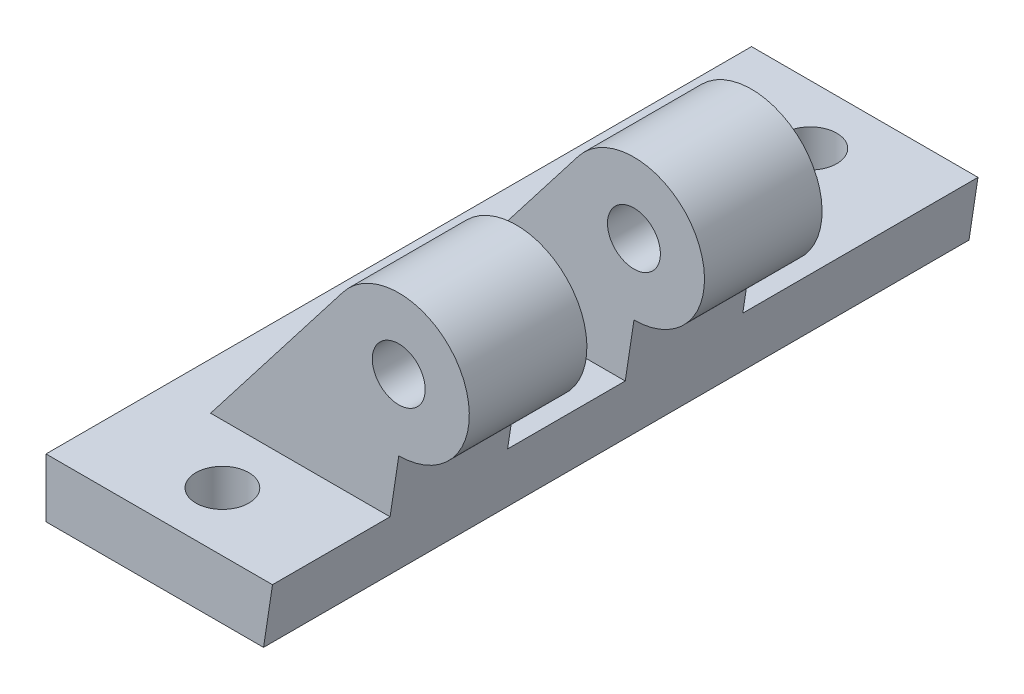
from build123d import *

# Parameters (mm, degrees)
SKETCH1_W           = 20
SKETCH1_H           = 60
SKETCH1_R           = 2.25
BOSS_EXTRUDE1_DEPTH = 5
SKETCH2_R           = 2.25
BOSS_EXTRUDE2_DEPTH = 10
SKETCH3_R           = 2.25
BOSS_EXTRUDE3_DEPTH = 10
CUT_EXTRUDE1_DEPTH  = 61


with BuildPart() as part:
    # Sketch1 → Boss-Extrude1 (new body)
    with BuildSketch(Plane(origin=(0, 0, 0), x_dir=(1, 0, 0), z_dir=(0, 1, 0))):
        Rectangle(SKETCH1_W, SKETCH1_H)
        with Locations((0, 25)):
            Circle(SKETCH1_R, mode=Mode.SUBTRACT)
        with Locations((0, -25)):
            Circle(SKETCH1_R, mode=Mode.SUBTRACT)
    extrude(amount=BOSS_EXTRUDE1_DEPTH)

    # Sketch2 → Boss-Extrude2 (add)
    with BuildSketch(Plane.XY.offset(20)):
        with BuildLine():
            Line((10, 9.86530346), (10, 5))
            Line((10, 5), (-6, 5))
            Line((-6, 5), (5.255684086, 19.53837663))
            ThreePointArc((5.255684086, 19.53837663), (15.386948998, 18.507420129), (10, 9.86530346))
        make_face()
        with Locations((10, 15.86530346)):
            Circle(SKETCH2_R, mode=Mode.SUBTRACT)
    extrude(amount=-BOSS_EXTRUDE2_DEPTH)

    # Sketch3 → Boss-Extrude3 (add)
    with BuildSketch(Plane(origin=(0, 0, -10), x_dir=(-1, 0, 0), z_dir=(0, 0, -1))):
        with BuildLine():
            Line((-10, 9.86530346), (-10, 5))
            Line((-10, 5), (6, 5))
            Line((6, 5), (-5.293415142, 19.586601483))
            ThreePointArc((-5.293415142, 19.586601483), (-15.40036055, 18.479898253), (-10, 9.86530346))
        make_face()
        with Locations((-10, 15.86530346)):
            Circle(SKETCH3_R, mode=Mode.SUBTRACT)
    extrude(amount=-BOSS_EXTRUDE3_DEPTH)

    # Sketch5 → Cut-Extrude1 (cut, through all)
    with BuildSketch(Plane(origin=(0, 0, -30), x_dir=(-1, 0, 0), z_dir=(0, 0, -1))):
        Polygon((-10, 9.86530346), (-10, 0), (-8.5, 0), align=None)
    extrude(amount=-CUT_EXTRUDE1_DEPTH, mode=Mode.SUBTRACT)


solid = part.part
